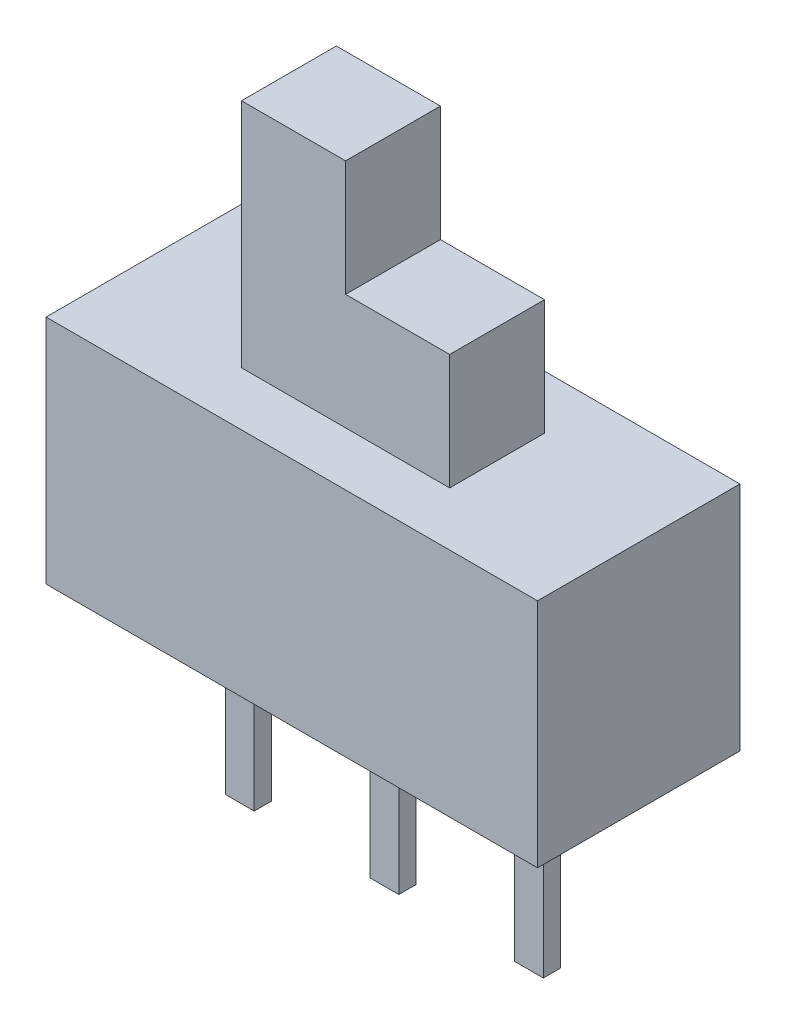
from build123d import *

# Parameters (mm, degrees)
SKETCH_1_W          = 8.5
SKETCH_1_H          = 3.5
EXTRUDE_1_DEPTH     = 4
SKETCH_2_W          = 3.6
SKETCH_2_H          = 1.64
EXTRUDE_2_DEPTH     = 4
SKETCH_3_W          = 1.8
SKETCH_3_H          = 1.64
CUT_EXTRUDE_1_DEPTH = 2
EXTRUDE_START       = -4
SKETCH_4_W          = 0.5
SKETCH_4_H          = 0.3
EXTRUDE_3_DEPTH     = 7.2


with BuildPart() as part:
    # 草图1 → 凸台-拉伸1 (new body)
    with BuildSketch(Plane(origin=(0, 0, 0), x_dir=(1, 0, 0), z_dir=(0, 1, 0))):
        Rectangle(SKETCH_1_W, SKETCH_1_H)
    extrude(amount=EXTRUDE_1_DEPTH)

    # 草图2 → 凸台-拉伸2 (add)
    with BuildSketch(Plane(origin=(0, 4, 0), x_dir=(1, 0, 0), z_dir=(0, 1, 0))):
        Rectangle(SKETCH_2_W, SKETCH_2_H)
    extrude(amount=EXTRUDE_2_DEPTH)

    # 草图3 → 切除-拉伸1 (cut)
    with BuildSketch(Plane(origin=(0, 8, 0), x_dir=(1, 0, 0), z_dir=(0, 1, 0))):
        with Locations((0.9, 0)):
            Rectangle(SKETCH_3_W, SKETCH_3_H)
    extrude(amount=-CUT_EXTRUDE_1_DEPTH, mode=Mode.SUBTRACT)

    # 草图4 → 凸台-拉伸3 (add)
    with BuildSketch(Plane.XZ.offset(EXTRUDE_START)):
        with Locations((2.5, 0)):
            Rectangle(SKETCH_4_W, SKETCH_4_H)
        Rectangle(SKETCH_4_W, SKETCH_4_H)
        with Locations((-2.5, 0)):
            Rectangle(SKETCH_4_W, SKETCH_4_H)
    extrude(amount=EXTRUDE_3_DEPTH)


solid = part.part
